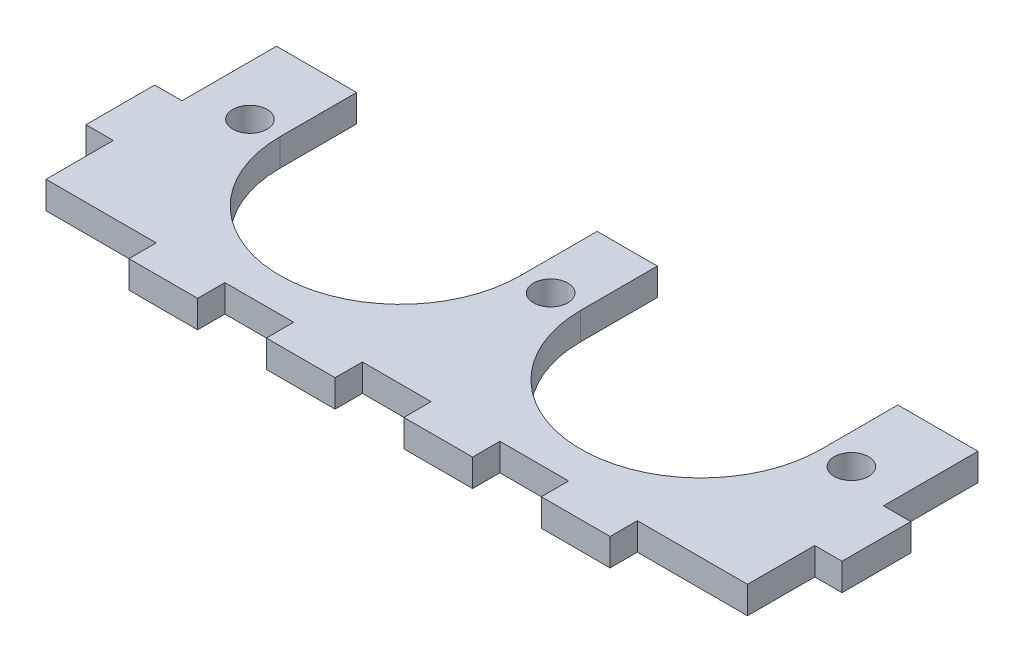
from build123d import *

# Parameters (mm, degrees)
SKETCH3_W           = 88
SKETCH3_H           = 30
BOSS_EXTRUDE1_DEPTH = 3.175
CUT_EXTRUDE1_REACH  = 5.175
SKETCH4_W           = 3.175
SKETCH4_H           = 7.825
SKETCH4_W_2         = 8
SKETCH4_H_2         = 3.175
SKETCH4_H_3         = 11
CUT_EXTRUDE2_REACH  = 5.175
SKETCH5_R           = 2


with BuildPart() as part:
    # Sketch3 → Boss-Extrude1 (new body)
    with BuildSketch(Plane(origin=(0, 0, 0), x_dir=(1, 0, 0), z_dir=(0, 1, 0))):
        with Locations((44, -15)):
            Rectangle(SKETCH3_W, SKETCH3_H)
    extrude(amount=BOSS_EXTRUDE1_DEPTH)

    # Sketch4 → Cut-Extrude1 (cut, up to next)
    with BuildSketch(Plane(origin=(0, 3.175, 0), x_dir=(1, 0, 0), z_dir=(0, 1, 0)), mode=Mode.PRIVATE) as cut_extrude1_sk1:
        with Locations((1.5875, -22.9125)):
            Rectangle(SKETCH4_W, SKETCH4_H)
    cut_extrude1_tool1 = extrude(cut_extrude1_sk1.sketch, amount=-CUT_EXTRUDE1_REACH, mode=Mode.PRIVATE) & part.part
    add(cut_extrude1_tool1.solids().sort_by_distance((1.5875, 3.175, 22.9125))[0], mode=Mode.SUBTRACT)
    # Sketch4 → Cut-Extrude1 (cut, up to next)
    with BuildSketch(Plane(origin=(0, 3.175, 0), x_dir=(1, 0, 0), z_dir=(0, 1, 0)), mode=Mode.PRIVATE) as cut_extrude1_sk2:
        Polygon((0, -30), (16, -30), (16, -26.825), (3.175, -26.825), (0, -26.825), align=None)
    cut_extrude1_tool2 = extrude(cut_extrude1_sk2.sketch, amount=-CUT_EXTRUDE1_REACH, mode=Mode.PRIVATE) & part.part
    add(cut_extrude1_tool2.solids().sort_by_distance((8, 3.175, 28.4125))[0], mode=Mode.SUBTRACT)
    # Sketch4 → Cut-Extrude1 (cut, up to next)
    with BuildSketch(Plane(origin=(0, 3.175, 0), x_dir=(1, 0, 0), z_dir=(0, 1, 0)), mode=Mode.PRIVATE) as cut_extrude1_sk3:
        with Locations((28, -28.4125)):
            Rectangle(SKETCH4_W_2, SKETCH4_H_2)
    cut_extrude1_tool3 = extrude(cut_extrude1_sk3.sketch, amount=-CUT_EXTRUDE1_REACH, mode=Mode.PRIVATE) & part.part
    add(cut_extrude1_tool3.solids().sort_by_distance((28, 3.175, 28.4125))[0], mode=Mode.SUBTRACT)
    # Sketch4 → Cut-Extrude1 (cut, up to next)
    with BuildSketch(Plane(origin=(0, 3.175, 0), x_dir=(1, 0, 0), z_dir=(0, 1, 0)), mode=Mode.PRIVATE) as cut_extrude1_sk4:
        with Locations((44, -28.4125)):
            Rectangle(SKETCH4_W_2, SKETCH4_H_2)
    cut_extrude1_tool4 = extrude(cut_extrude1_sk4.sketch, amount=-CUT_EXTRUDE1_REACH, mode=Mode.PRIVATE) & part.part
    add(cut_extrude1_tool4.solids().sort_by_distance((44, 3.175, 28.4125))[0], mode=Mode.SUBTRACT)
    # Sketch4 → Cut-Extrude1 (cut, up to next)
    with BuildSketch(Plane(origin=(0, 3.175, 0), x_dir=(1, 0, 0), z_dir=(0, 1, 0)), mode=Mode.PRIVATE) as cut_extrude1_sk5:
        with Locations((60, -28.4125)):
            Rectangle(SKETCH4_W_2, SKETCH4_H_2)
    cut_extrude1_tool5 = extrude(cut_extrude1_sk5.sketch, amount=-CUT_EXTRUDE1_REACH, mode=Mode.PRIVATE) & part.part
    add(cut_extrude1_tool5.solids().sort_by_distance((60, 3.175, 28.4125))[0], mode=Mode.SUBTRACT)
    # Sketch4 → Cut-Extrude1 (cut, up to next)
    with BuildSketch(Plane(origin=(0, 3.175, 0), x_dir=(1, 0, 0), z_dir=(0, 1, 0)), mode=Mode.PRIVATE) as cut_extrude1_sk6:
        with Locations((86.4125, -22.9125)):
            Rectangle(SKETCH4_W, SKETCH4_H)
    cut_extrude1_tool6 = extrude(cut_extrude1_sk6.sketch, amount=-CUT_EXTRUDE1_REACH, mode=Mode.PRIVATE) & part.part
    add(cut_extrude1_tool6.solids().sort_by_distance((86.4125, 3.175, 22.9125))[0], mode=Mode.SUBTRACT)
    # Sketch4 → Cut-Extrude1 (cut, up to next)
    with BuildSketch(Plane(origin=(0, 3.175, 0), x_dir=(1, 0, 0), z_dir=(0, 1, 0)), mode=Mode.PRIVATE) as cut_extrude1_sk7:
        with Locations((86.4125, -5.5)):
            Rectangle(SKETCH4_W, SKETCH4_H_3)
    cut_extrude1_tool7 = extrude(cut_extrude1_sk7.sketch, amount=-CUT_EXTRUDE1_REACH, mode=Mode.PRIVATE) & part.part
    add(cut_extrude1_tool7.solids().sort_by_distance((86.4125, 3.175, 5.5))[0], mode=Mode.SUBTRACT)
    # Sketch4 → Cut-Extrude1 (cut, up to next)
    with BuildSketch(Plane(origin=(0, 3.175, 0), x_dir=(1, 0, 0), z_dir=(0, 1, 0)), mode=Mode.PRIVATE) as cut_extrude1_sk8:
        Polygon((72, -26.825), (72, -30), (88, -30), (88, -26.825), (84.825, -26.825), align=None)
    cut_extrude1_tool8 = extrude(cut_extrude1_sk8.sketch, amount=-CUT_EXTRUDE1_REACH, mode=Mode.PRIVATE) & part.part
    add(cut_extrude1_tool8.solids().sort_by_distance((80, 3.175, 28.4125))[0], mode=Mode.SUBTRACT)
    # Sketch4 → Cut-Extrude1 (cut, up to next)
    with BuildSketch(Plane(origin=(0, 3.175, 0), x_dir=(1, 0, 0), z_dir=(0, 1, 0)), mode=Mode.PRIVATE) as cut_extrude1_sk9:
        with Locations((1.5875, -5.5)):
            Rectangle(SKETCH4_W, SKETCH4_H_3)
    cut_extrude1_tool9 = extrude(cut_extrude1_sk9.sketch, amount=-CUT_EXTRUDE1_REACH, mode=Mode.PRIVATE) & part.part
    add(cut_extrude1_tool9.solids().sort_by_distance((1.5875, 3.175, 5.5))[0], mode=Mode.SUBTRACT)

    # Sketch5 → Cut-Extrude2 (cut, up to next)
    with BuildSketch(Plane(origin=(0, 3.175, 0), x_dir=(1, 0, 0), z_dir=(0, 1, 0)), mode=Mode.PRIVATE) as cut_extrude2_sk1:
        with Locations((44, -8.9125)):
            Circle(SKETCH5_R)
    cut_extrude2_tool1 = extrude(cut_extrude2_sk1.sketch, amount=-CUT_EXTRUDE2_REACH, mode=Mode.PRIVATE) & part.part
    add(cut_extrude2_tool1.solids().sort_by_distance((44, 3.175, 8.9125))[0], mode=Mode.SUBTRACT)
    # Sketch5 → Cut-Extrude2 (cut, up to next)
    with BuildSketch(Plane(origin=(0, 3.175, 0), x_dir=(1, 0, 0), z_dir=(0, 1, 0)), mode=Mode.PRIVATE) as cut_extrude2_sk2:
        with Locations((9, -8.9125)):
            Circle(SKETCH5_R)
    cut_extrude2_tool2 = extrude(cut_extrude2_sk2.sketch, amount=-CUT_EXTRUDE2_REACH, mode=Mode.PRIVATE) & part.part
    add(cut_extrude2_tool2.solids().sort_by_distance((9, 3.175, 8.9125))[0], mode=Mode.SUBTRACT)
    # Sketch5 → Cut-Extrude2 (cut, up to next)
    with BuildSketch(Plane(origin=(0, 3.175, 0), x_dir=(1, 0, 0), z_dir=(0, 1, 0)), mode=Mode.PRIVATE) as cut_extrude2_sk3:
        with Locations((79, -8.9125)):
            Circle(SKETCH5_R)
    cut_extrude2_tool3 = extrude(cut_extrude2_sk3.sketch, amount=-CUT_EXTRUDE2_REACH, mode=Mode.PRIVATE) & part.part
    add(cut_extrude2_tool3.solids().sort_by_distance((79, 3.175, 8.9125))[0], mode=Mode.SUBTRACT)
    # Sketch5 → Cut-Extrude2 (cut, up to next)
    with BuildSketch(Plane(origin=(0, 3.175, 0), x_dir=(1, 0, 0), z_dir=(0, 1, 0)), mode=Mode.PRIVATE) as cut_extrude2_sk4:
        with BuildLine():
            Line((75.5, -8.9125), (75.5, 0))
            Line((75.5, 0), (47.5, 0))
            Line((47.5, 0), (47.5, -8.9125))
            ThreePointArc((47.5, -8.9125), (61.5, -22.9125), (75.5, -8.9125))
        make_face()
    cut_extrude2_tool4 = extrude(cut_extrude2_sk4.sketch, amount=-CUT_EXTRUDE2_REACH, mode=Mode.PRIVATE) & part.part
    add(cut_extrude2_tool4.solids().sort_by_distance((61.5, 3.175, 10.199265))[0], mode=Mode.SUBTRACT)
    # Sketch5 → Cut-Extrude2 (cut, up to next)
    with BuildSketch(Plane(origin=(0, 3.175, 0), x_dir=(1, 0, 0), z_dir=(0, 1, 0)), mode=Mode.PRIVATE) as cut_extrude2_sk5:
        with BuildLine():
            Line((12.5, -8.9125), (12.5, 0))
            Line((12.5, 0), (40.5, 0))
            Line((40.5, 0), (40.5, -8.9125))
            ThreePointArc((40.5, -8.9125), (26.5, -22.9125), (12.5, -8.9125))
        make_face()
    cut_extrude2_tool5 = extrude(cut_extrude2_sk5.sketch, amount=-CUT_EXTRUDE2_REACH, mode=Mode.PRIVATE) & part.part
    add(cut_extrude2_tool5.solids().sort_by_distance((26.5, 3.175, 10.199265))[0], mode=Mode.SUBTRACT)


solid = part.part
